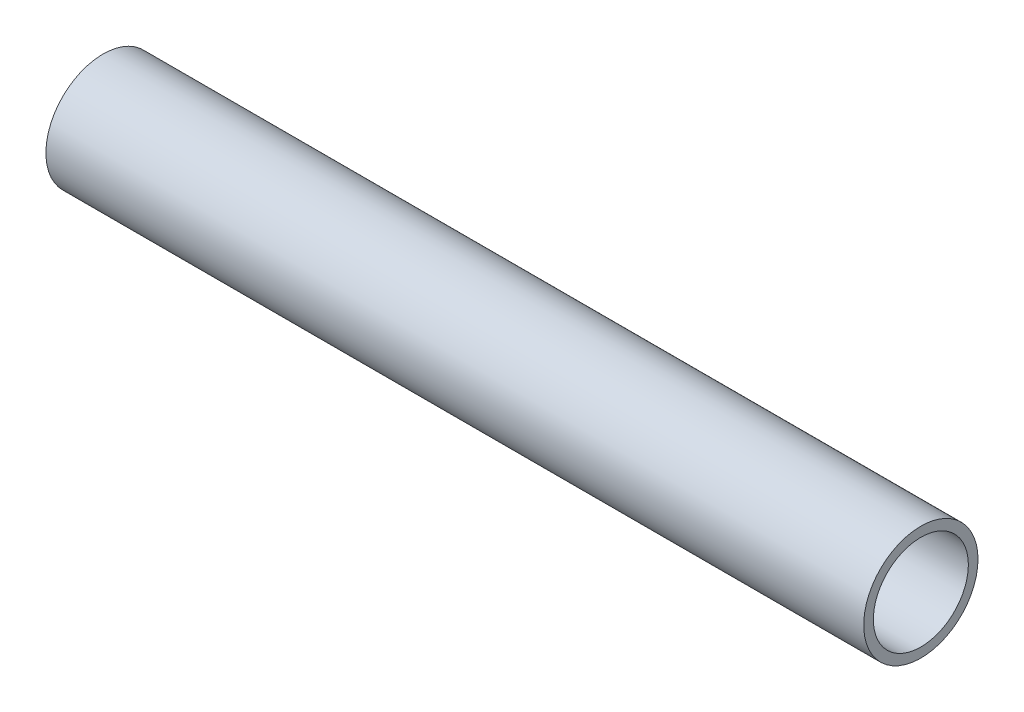
from build123d import *

# Parameters (mm, degrees)
SKETCH1_R                = 21.082
SKETCH1_R_2              = 17.526
BOSS_EXTRUDE1_DEPTH      = 127
BOSS_EXTRUDE1_DEPTH_BACK = 174.625
SKETCH2_R                = 3.175
CUT_EXTRUDE1_DEPTH       = 22.082


with BuildPart() as part:
    # Sketch1 → Boss-Extrude1 (new body, two sides)
    with BuildSketch(Plane(origin=(0, 0, 0), x_dir=(0, 0, -1), z_dir=(1, 0, 0))) as boss_extrude1_sk:
        Circle(SKETCH1_R)
        Circle(SKETCH1_R_2, mode=Mode.SUBTRACT)
    extrude(amount=BOSS_EXTRUDE1_DEPTH)
    extrude(boss_extrude1_sk.sketch, amount=-BOSS_EXTRUDE1_DEPTH_BACK)

    # Sketch2 → Cut-Extrude1 (cut, through all)
    with BuildSketch(Plane.XY):
        with Locations((-98.425, 0)):
            Circle(SKETCH2_R)
        with Locations((-149.225, 0)):
            Circle(SKETCH2_R)
    extrude(amount=-CUT_EXTRUDE1_DEPTH, mode=Mode.SUBTRACT)


solid = part.part
